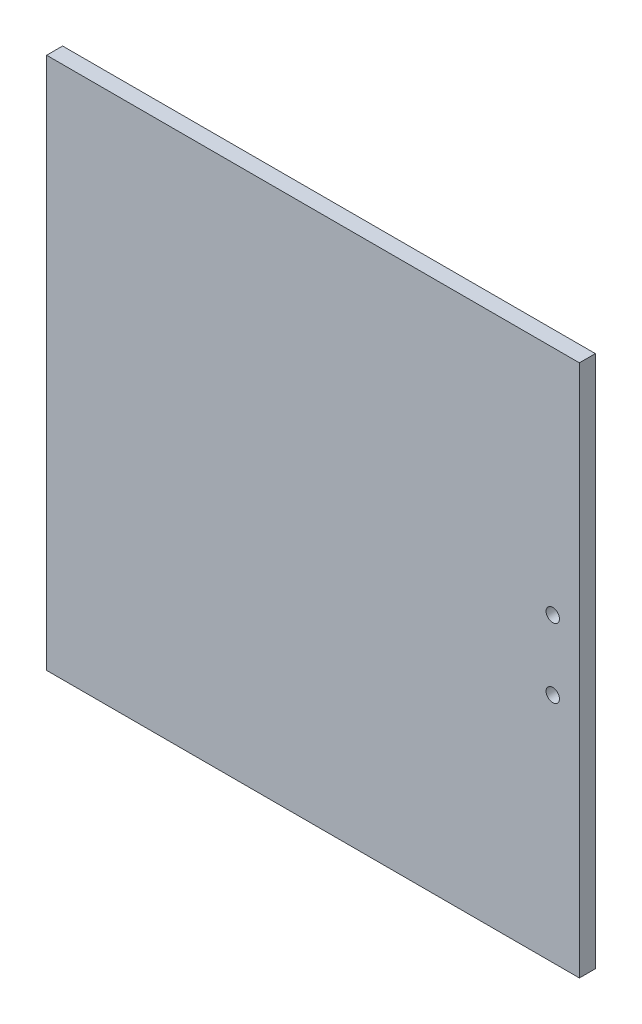
from build123d import *

# Parameters (mm, degrees)
SKETCH1_W           = 200
SKETCH1_H           = 200
SKETCH1_R           = 2.5
BOSS_EXTRUDE1_DEPTH = 6


with BuildPart() as part:
    # Sketch1 → Boss-Extrude1 (new body)
    with BuildSketch(Plane.XY):
        Rectangle(SKETCH1_W, SKETCH1_H)
        with Locations((90, 13)):
            Circle(SKETCH1_R, mode=Mode.SUBTRACT)
        with Locations((90, -13)):
            Circle(SKETCH1_R, mode=Mode.SUBTRACT)
    extrude(amount=BOSS_EXTRUDE1_DEPTH)


solid = part.part
